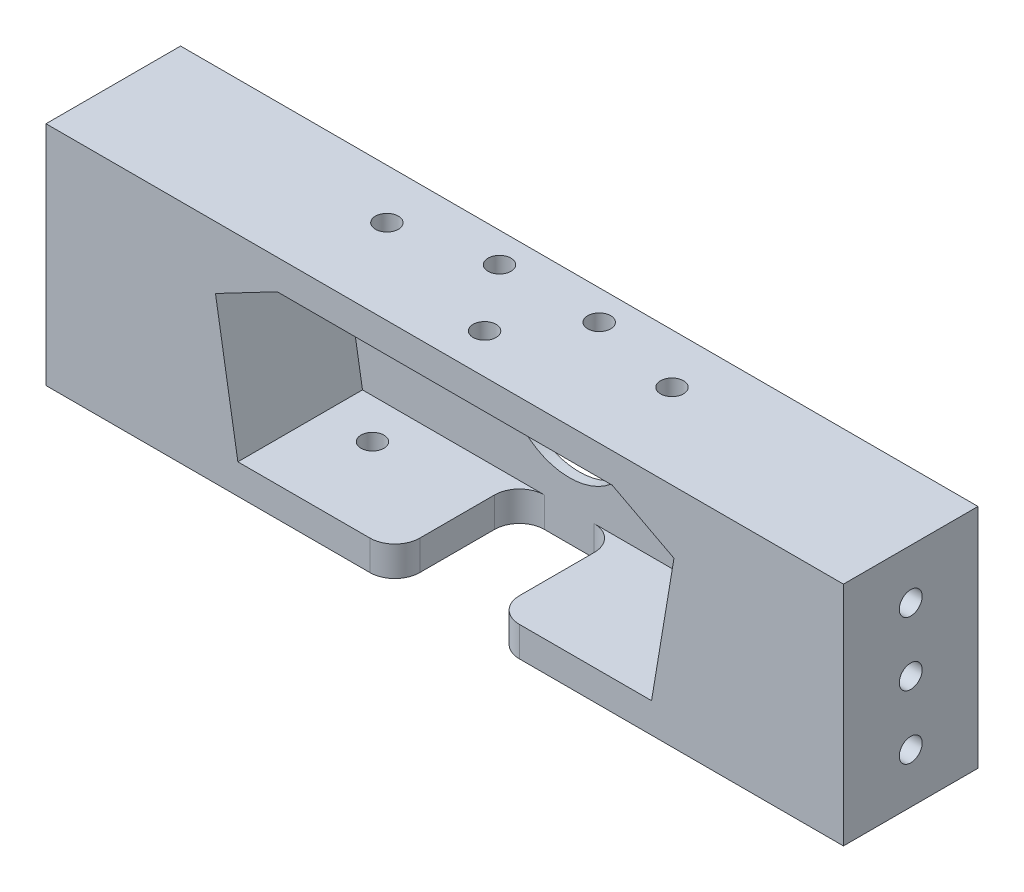
from build123d import *

# Parameters (mm, degrees)
CROQUIS1_W              = 160
CROQUIS1_H              = 45.5
SALIENTE_EXTRUIR1_DEPTH = 25
CROQUIS2_W              = 160
CROQUIS2_H              = 45.5
SALIENTE_EXTRUIR2_DEPTH = 2
CROQUIS5_R              = 13
CORTAR_EXTRUIR3_DEPTH   = 2
CORTAR_EXTRUIR4_REACH   = 8
CROQUIS6_W              = 20
CROQUIS6_H              = 25
REDONDEO1_R             = 5
REDONDEO2_R             = 5
CORTAR_EXTRUIR5_REACH   = 8
CROQUIS7_R              = 2.3
CORTAR_EXTRUIR6_REACH   = 8
CROQUIS8_R              = 2.3
CORTAR_EXTRUIR7_REACH   = 47.5
CROQUIS9_R              = 2.3
CROQUIS10_R             = 2.3
CORTAR_EXTRUIR8_DEPTH   = 20
CROQUIS11_R             = 2.3
CORTAR_EXTRUIR9_DEPTH   = 20


with BuildPart() as part:
    # Croquis1 → Saliente-Extruir1 (new body)
    with BuildSketch(Plane.XY):
        Rectangle(CROQUIS1_W, CROQUIS1_H)
        Polygon((-33.600403232, 16.75), (33.600403232, 16.75), (46, 10.25), (41.5, -16.75), (-41.5, -16.75), (-46, 10.25), align=None, mode=Mode.SUBTRACT)
    extrude(amount=SALIENTE_EXTRUIR1_DEPTH)

    # Croquis2 → Saliente-Extruir2 (add)
    with BuildSketch(Plane(origin=(0, 0, 0), x_dir=(-1, 0, 0), z_dir=(0, 0, -1))):
        Rectangle(CROQUIS2_W, CROQUIS2_H)
    extrude(amount=SALIENTE_EXTRUIR2_DEPTH)

    # Croquis5 → Cortar-Extruir3 (cut)
    with BuildSketch(Plane.XY):
        with Locations((0, 1.75)):
            Circle(CROQUIS5_R)
    extrude(amount=-CORTAR_EXTRUIR3_DEPTH, mode=Mode.SUBTRACT)

    # Croquis6 → Cortar-Extruir4 (cut, up to next)
    with BuildSketch(Plane(origin=(0, -16.75, 0), x_dir=(1, 0, 0), z_dir=(0, 1, 0)), mode=Mode.PRIVATE) as cortar_extruir4_sk1:
        with Locations((0, -12.5)):
            Rectangle(CROQUIS6_W, CROQUIS6_H)
    cortar_extruir4_tool1 = extrude(cortar_extruir4_sk1.sketch, amount=-CORTAR_EXTRUIR4_REACH, mode=Mode.PRIVATE) & part.part
    add(cortar_extruir4_tool1.solids().sort_by_distance((0, -16.75, 12.5))[0], mode=Mode.SUBTRACT)

    # Redondeo1
    redondeo1_edges = [part.edges().sort_by_distance(p)[0] for p in [
        (-10, -19.75, 0),
        (10, -19.75, 0),
    ]]
    fillet(redondeo1_edges, radius=REDONDEO1_R)

    # Redondeo2
    redondeo2_edges = [part.edges().sort_by_distance(p)[0] for p in [
        (-10, -19.75, 25),
        (10, -19.75, 25),
    ]]
    fillet(redondeo2_edges, radius=REDONDEO2_R)

    # Croquis7 → Cortar-Extruir5 (cut, up to next)
    with BuildSketch(Plane(origin=(0, -16.75, 0), x_dir=(1, 0, 0), z_dir=(0, 1, 0)), mode=Mode.PRIVATE) as cortar_extruir5_sk1:
        with Locations((-31.5, -8)):
            Circle(CROQUIS7_R)
    cortar_extruir5_tool1 = extrude(cortar_extruir5_sk1.sketch, amount=-CORTAR_EXTRUIR5_REACH, mode=Mode.PRIVATE) & part.part
    add(cortar_extruir5_tool1.solids().sort_by_distance((-31.5, -16.75, 8))[0], mode=Mode.SUBTRACT)
    # Croquis7 → Cortar-Extruir5 (cut, up to next)
    with BuildSketch(Plane(origin=(0, -16.75, 0), x_dir=(1, 0, 0), z_dir=(0, 1, 0)), mode=Mode.PRIVATE) as cortar_extruir5_sk2:
        with Locations((31.5, -8)):
            Circle(CROQUIS7_R)
    cortar_extruir5_tool2 = extrude(cortar_extruir5_sk2.sketch, amount=-CORTAR_EXTRUIR5_REACH, mode=Mode.PRIVATE) & part.part
    add(cortar_extruir5_tool2.solids().sort_by_distance((31.5, -16.75, 8))[0], mode=Mode.SUBTRACT)

    # Croquis8 → Cortar-Extruir6 (cut, up to next)
    with BuildSketch(Plane.XZ.offset(-16.75), mode=Mode.PRIVATE) as cortar_extruir6_sk1:
        with Locations((-28.600403232, 8)):
            Circle(CROQUIS8_R)
    cortar_extruir6_tool1 = extrude(cortar_extruir6_sk1.sketch, amount=-CORTAR_EXTRUIR6_REACH, mode=Mode.PRIVATE) & part.part
    add(cortar_extruir6_tool1.solids().sort_by_distance((-28.600403, 16.75, 8))[0], mode=Mode.SUBTRACT)
    # Croquis8 → Cortar-Extruir6 (cut, up to next)
    with BuildSketch(Plane.XZ.offset(-16.75), mode=Mode.PRIVATE) as cortar_extruir6_sk2:
        with Locations((28.600403232, 8)):
            Circle(CROQUIS8_R)
    cortar_extruir6_tool2 = extrude(cortar_extruir6_sk2.sketch, amount=-CORTAR_EXTRUIR6_REACH, mode=Mode.PRIVATE) & part.part
    add(cortar_extruir6_tool2.solids().sort_by_distance((28.600403, 16.75, 8))[0], mode=Mode.SUBTRACT)

    # Croquis9 → Cortar-Extruir7 (cut, up to next)
    with BuildSketch(Plane(origin=(0, 22.75, 0), x_dir=(1, 0, 0), z_dir=(0, 1, 0)), mode=Mode.PRIVATE) as cortar_extruir7_sk1:
        with Locations((-10, -4)):
            Circle(CROQUIS9_R)
    cortar_extruir7_tool1 = extrude(cortar_extruir7_sk1.sketch, amount=-CORTAR_EXTRUIR7_REACH, mode=Mode.PRIVATE) & part.part
    add(cortar_extruir7_tool1.solids().sort_by_distance((-10, 22.75, 4))[0], mode=Mode.SUBTRACT)
    # Croquis9 → Cortar-Extruir7 (cut, up to next)
    with BuildSketch(Plane(origin=(0, 22.75, 0), x_dir=(1, 0, 0), z_dir=(0, 1, 0)), mode=Mode.PRIVATE) as cortar_extruir7_sk2:
        with Locations((10, -4)):
            Circle(CROQUIS9_R)
    cortar_extruir7_tool2 = extrude(cortar_extruir7_sk2.sketch, amount=-CORTAR_EXTRUIR7_REACH, mode=Mode.PRIVATE) & part.part
    add(cortar_extruir7_tool2.solids().sort_by_distance((10, 22.75, 4))[0], mode=Mode.SUBTRACT)
    # Croquis9 → Cortar-Extruir7 (cut, up to next)
    with BuildSketch(Plane(origin=(0, 22.75, 0), x_dir=(1, 0, 0), z_dir=(0, 1, 0)), mode=Mode.PRIVATE) as cortar_extruir7_sk3:
        with Locations((0, -17)):
            Circle(CROQUIS9_R)
    cortar_extruir7_tool3 = extrude(cortar_extruir7_sk3.sketch, amount=-CORTAR_EXTRUIR7_REACH, mode=Mode.PRIVATE) & part.part
    add(cortar_extruir7_tool3.solids().sort_by_distance((0, 22.75, 17))[0], mode=Mode.SUBTRACT)

    # Croquis10 → Cortar-Extruir8 (cut)
    with BuildSketch(Plane.ZY.offset(80)):
        with Locations((11.5, 0)):
            Circle(CROQUIS10_R)
        with Locations((11.5, -12.75)):
            Circle(CROQUIS10_R)
        with Locations((11.5, 12.75)):
            Circle(CROQUIS10_R)
    extrude(amount=-CORTAR_EXTRUIR8_DEPTH, mode=Mode.SUBTRACT)

    # Croquis11 → Cortar-Extruir9 (cut)
    with BuildSketch(Plane(origin=(80, 0, 0), x_dir=(0, 0, -1), z_dir=(1, 0, 0))):
        with Locations((-11.5, 12.75)):
            Circle(CROQUIS11_R)
        with Locations((-11.5, 0)):
            Circle(CROQUIS11_R)
        with Locations((-11.5, -12.75)):
            Circle(CROQUIS11_R)
    extrude(amount=-CORTAR_EXTRUIR9_DEPTH, mode=Mode.SUBTRACT)


solid = part.part
